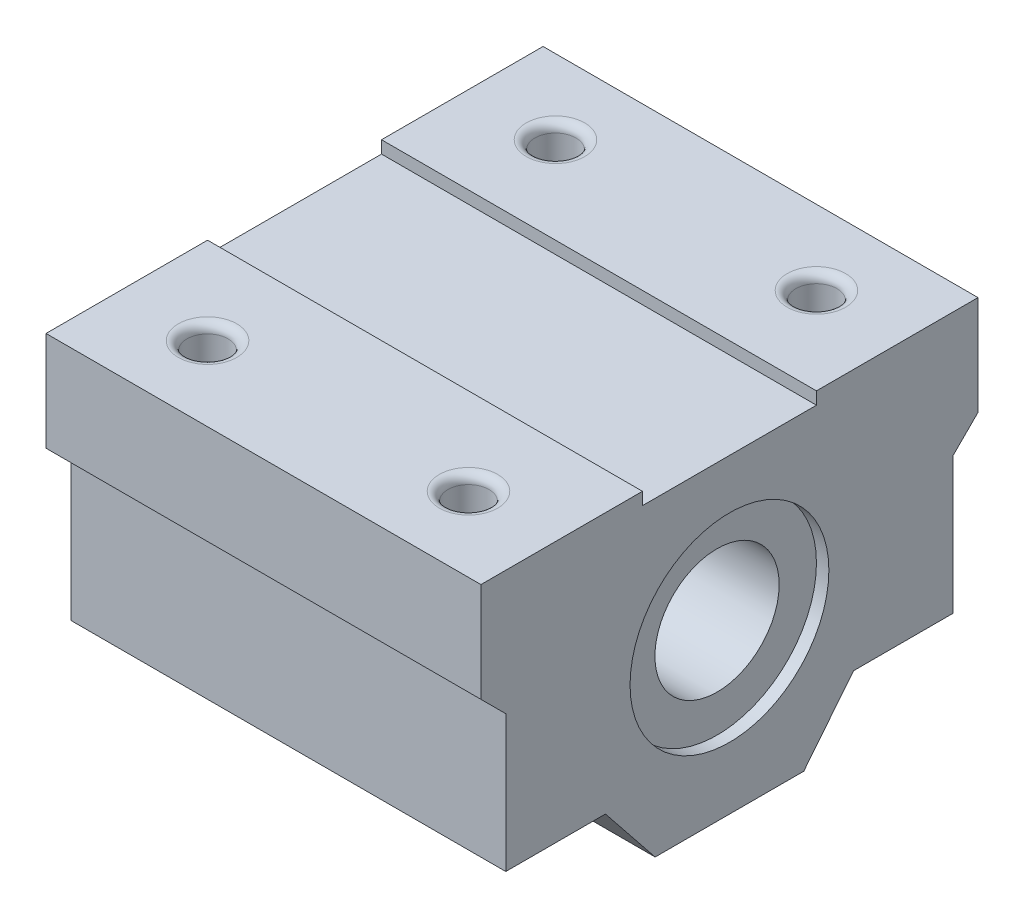
from build123d import *

# Parameters (mm, degrees)
BOSS_EXTRUDE1_DEPTH = 17.5
SKETCH2_R           = 5
CUT_EXTRUDE1_DEPTH  = 36
SKETCH3_R           = 1.65
CUT_EXTRUDE2_DEPTH  = 27
FILLET1_R           = 0.7
SKETCH8_R           = 8
CUT_EXTRUDE5_DEPTH  = 1


with BuildPart() as part:
    # Sketch1 → Boss-Extrude1 (new body, symmetric)
    with BuildSketch(Plane(origin=(0, 0, 0), x_dir=(0, 0, -1), z_dir=(1, 0, 0))):
        Polygon((-20, 26), (-7, 26), (-7, 25), (7, 25), (7, 26), (20, 26), (20, 18), (18, 16), (18, 5), (9.980120734, 5), (5.980120734, 0), (-5.980120734, 0), (-9.980120734, 5), (-18, 5), (-18, 16), (-20, 18), align=None)
    extrude(amount=BOSS_EXTRUDE1_DEPTH, both=True)

    # Sketch2 → Cut-Extrude1 (cut, through all)
    with BuildSketch(Plane(origin=(17.5, 0, 0), x_dir=(0, 0, -1), z_dir=(1, 0, 0))):
        with Locations((0, 13)):
            Circle(SKETCH2_R)
    extrude(amount=-CUT_EXTRUDE1_DEPTH, mode=Mode.SUBTRACT)

    # Sketch3 → Cut-Extrude2 (cut, through all)
    with BuildSketch(Plane(origin=(0, 26, 0), x_dir=(1, 0, 0), z_dir=(0, 1, 0))):
        with Locations((-10.5, 14)):
            Circle(SKETCH3_R)
        with Locations((10.5, 14)):
            Circle(SKETCH3_R)
        with Locations((10.5, -14)):
            Circle(SKETCH3_R)
        with Locations((-10.5, -14)):
            Circle(SKETCH3_R)
    extrude(amount=-CUT_EXTRUDE2_DEPTH, mode=Mode.SUBTRACT)

    # Fillet1
    fillet1_edges = [part.edges().sort_by_distance(p)[0] for p in [
        (-12.15, 26, -14),
        (8.85, 26, -14),
        (8.85, 26, 14),
        (-12.15, 26, 14),
    ]]
    fillet(fillet1_edges, radius=FILLET1_R)

    # Sketch8 → Cut-Extrude5 (cut)
    with BuildSketch(Plane(origin=(17.5, 0, 0), x_dir=(0, 0, -1), z_dir=(1, 0, 0))):
        with Locations((0, 13)):
            Circle(SKETCH8_R)
    cut_extrude5 = extrude(amount=-CUT_EXTRUDE5_DEPTH, mode=Mode.SUBTRACT)

    # Mirror3: Cut-Extrude5 across plane
    add(cut_extrude5.mirror(Plane(origin=(0, 0, 0), x_dir=(0, 0, 1), z_dir=(1, 0, 0))), mode=Mode.SUBTRACT)


solid = part.part
